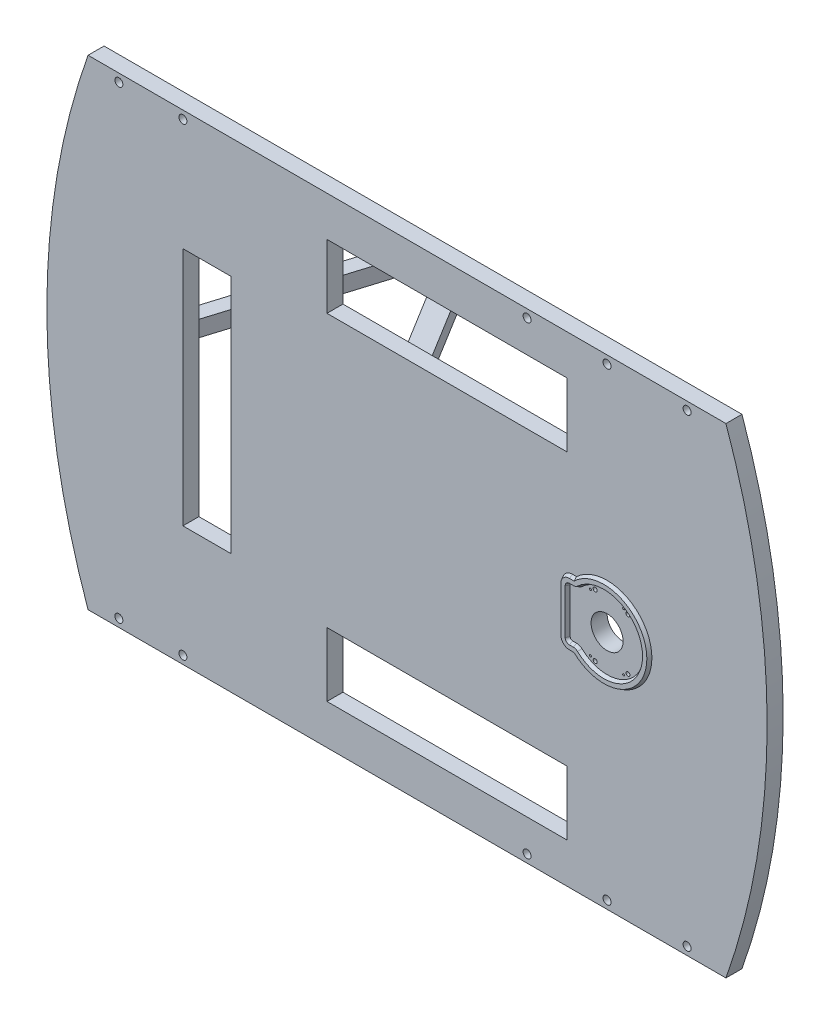
from build123d import *

# Parameters (mm, degrees)
SKETCH_1_W           = 900
SKETCH_1_H           = 600
EXTRUDE_1_DEPTH      = 20
SKETCH_2_W           = 1200.878029557
SKETCH_2_H           = 2000
CUT_EXTRUDE_1_DEPTH  = 20
EXTRUDE_2_DEPTH      = 4
EXTRUDE_2_DRAFT      = 30
SKETCH_4_R           = 2.5
SKETCH_4_R_2         = 1.25
CUT_EXTRUDE_2_DEPTH  = 15
SKETCH_5_R           = 20
SKETCH_5_W           = 300
SKETCH_5_H           = 80
SKETCH_5_W_2         = 60
SKETCH_5_H_2         = 300
CUT_EXTRUDE_3_DEPTH  = 762.83987819
EXTRUDE_3_DEPTH      = 10
EXTRUDE_3_DEPTH_BACK = 10
SKETCH_7_R           = 5
CUT_EXTRUDE_4_DEPTH  = 807.037219984
SKETCH_8_R           = 5
CUT_EXTRUDE_5_DEPTH  = 812.418511004


with BuildPart() as part:
    # 草图1 → 凸台-拉伸1 (new body)
    with BuildSketch(Plane.XY):
        with Locations((-250, 0)):
            Rectangle(SKETCH_1_W, SKETCH_1_H)
    extrude(amount=-EXTRUDE_1_DEPTH)

    # 草图2 → 切除-拉伸1 (cut)
    with BuildSketch(Plane.XY):
        with Locations((-145.818669814, 100)):
            Rectangle(SKETCH_2_W, SKETCH_2_H)
        with BuildLine():
            ThreePointArc((-250, -779.422863406), (200, 0), (-250, 779.422863406))
            ThreePointArc((-250, 779.422863406), (-700, 0), (-250, -779.422863406))
        make_face(mode=Mode.SUBTRACT)
    extrude(amount=-CUT_EXTRUDE_1_DEPTH, mode=Mode.SUBTRACT)

    # 草图4 → 切除-拉伸2 (cut)
    with BuildSketch(Plane.XY):
        with Locations((26.116796229, 32.2515574)):
            Circle(SKETCH_4_R)
        with Locations((20.75, 35.940054257)):
            Circle(SKETCH_4_R_2)
        with Locations((-14.872269906, 38.7435877)):
            Circle(SKETCH_4_R)
        with Locations((-20.75, 35.940054257)):
            Circle(SKETCH_4_R_2)
    cut_extrude_2 = extrude(amount=-CUT_EXTRUDE_2_DEPTH, mode=Mode.SUBTRACT)

    # 镜向1: 切除-拉伸2 across plane
    add(cut_extrude_2.mirror(Plane.ZX), mode=Mode.SUBTRACT)

    # 草图5 → 切除-拉伸3 (cut, through all)
    with BuildSketch(Plane.XY):
        Circle(SKETCH_5_R)
        with Locations((-200, 210)):
            Rectangle(SKETCH_5_W, SKETCH_5_H)
        with Locations((-200, -210)):
            Rectangle(SKETCH_5_W, SKETCH_5_H)
        with Locations((-500, 0)):
            Rectangle(SKETCH_5_W_2, SKETCH_5_H_2)
    extrude(amount=-CUT_EXTRUDE_3_DEPTH, mode=Mode.SUBTRACT)

    # 草图8 → 切除-拉伸5 (cut, through all)
    with BuildSketch(Plane.XY):
        with Locations((0, 290)):
            Circle(SKETCH_8_R)
        with Locations((100, 290)):
            Circle(SKETCH_8_R)
        with Locations((-100, 290)):
            Circle(SKETCH_8_R)
        with Locations((-610, 290)):
            Circle(SKETCH_8_R)
        with Locations((-530, 290)):
            Circle(SKETCH_8_R)
    cut_extrude_5 = extrude(amount=-CUT_EXTRUDE_5_DEPTH, mode=Mode.SUBTRACT)

    # 镜向2: 切除-拉伸5 across plane
    add(cut_extrude_5.mirror(Plane.ZX), mode=Mode.SUBTRACT)


with BuildPart() as body_2:
    # 草图3 → 凸台-拉伸2 (with draft: the straight prism first)
    with BuildSketch(Plane.XY):
        with BuildLine():
            Line((-56.05, 28), (-56.05, -28))
            ThreePointArc((-56.05, -28), (-52.242388155, -37.192388155), (-43.05, -41))
            Line((-43.05, -41), (-38.144462246, -41))
            ThreePointArc((-38.144462246, -41), (56, 0), (-38.144462246, 41))
            Line((-38.144462246, 41), (-43.05, 41))
            ThreePointArc((-43.05, 41), (-52.242388155, 37.192388155), (-56.05, 28))
        make_face()
        with BuildLine():
            Line((-46.05, 28), (-46.05, -28))
            ThreePointArc((-46.05, -28), (-45.171320344, -30.121320344), (-43.05, -31))
            Line((-43.05, -31), (-38.144462246, -31))
            ThreePointArc((-38.144462246, -31), (-34.484836972, -31.693704128), (-31.33295113, -33.678571429))
            ThreePointArc((-31.33295113, -33.678571429), (46, 0), (-31.33295113, 33.678571429))
            ThreePointArc((-31.33295113, 33.678571429), (-34.484836972, 31.693704128), (-38.144462246, 31))
            Line((-38.144462246, 31), (-43.05, 31))
            ThreePointArc((-43.05, 31), (-45.171320344, 30.121320344), (-46.05, 28))
        make_face(mode=Mode.SUBTRACT)
    extrude(amount=EXTRUDE_2_DEPTH)
    # 凸台-拉伸2: the draft: its side faces are tilted about the plane it starts from
    extrude_2_sides = [body_2.faces().sort_by_distance(p)[0] for p in [
        (-40.597231123, 41, 2),
        (-52.242388155, 37.192388155, 2),
        (-56.05, 0, 2),
        (-52.242388155, -37.192388155, 2),
        (-40.597231123, -41, 2),
        (56, 0, 2),
        (-40.597231123, 31, 2),
        (-34.484836972, 31.693704128, 2),
        (46, 0, 2),
        (-34.484836972, -31.693704128, 2),
        (-40.597231123, -31, 2),
        (-45.171320344, -30.121320344, 2),
        (-46.05, 0, 2),
        (-45.171320344, 30.121320344, 2),
    ]]
    draft(extrude_2_sides, Plane.XY, EXTRUDE_2_DRAFT)


with BuildPart() as body_3:
    # 草图6 → 凸台-拉伸3 (new, two sides)
    with BuildSketch(Plane(origin=(0, 0, 0), x_dir=(1, 0, 0), z_dir=(0, 1, 0))) as extrude_3_sk:
        Polygon((-620, 20), (-600, 20), (-526.153846154, 260), (-477.692307692, 260), (-330, 20), (-300, 20), (-460, 280), (-540, 280), align=None)
    extrude(amount=EXTRUDE_3_DEPTH)
    extrude(extrude_3_sk.sketch, amount=-EXTRUDE_3_DEPTH_BACK)

    # 草图7 → 切除-拉伸4 (cut, through all)
    with BuildSketch(Plane.XY.offset(-260)):
        with Locations((-516.153846154, 0)):
            Circle(SKETCH_7_R)
        with Locations((-487.692307692, 0)):
            Circle(SKETCH_7_R)
    extrude(amount=-CUT_EXTRUDE_4_DEPTH, mode=Mode.SUBTRACT)


solid = Compound([part.part, body_2.part, body_3.part])
